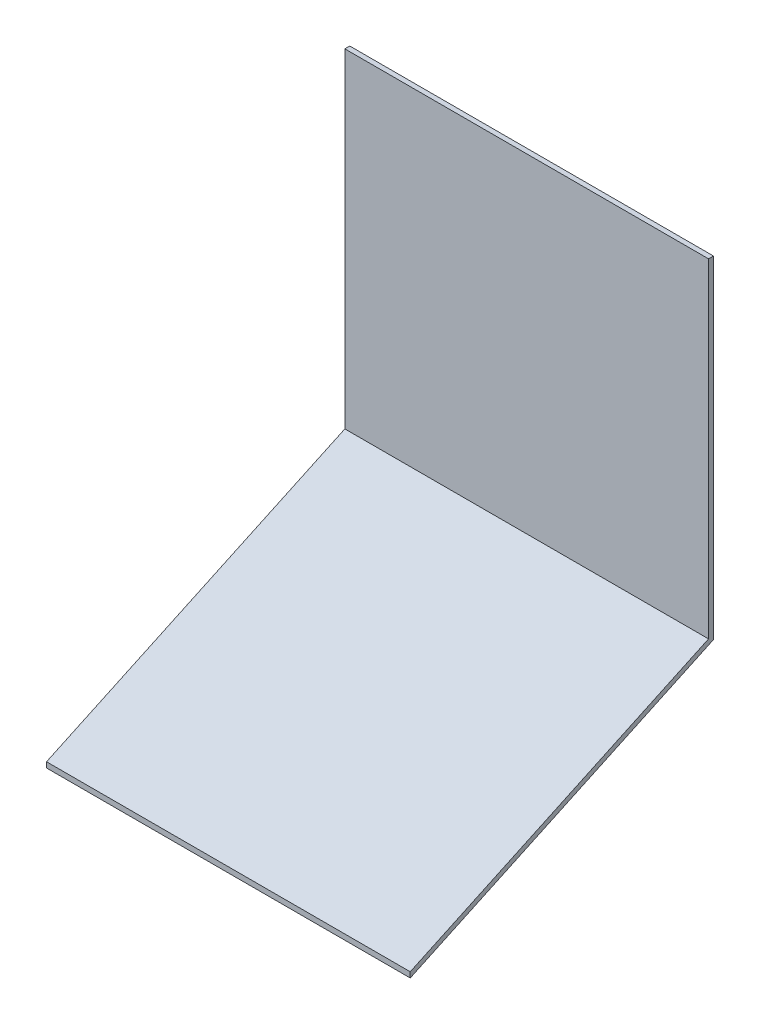
from build123d import *

# Parameters (mm, degrees)
BOSS_EXTRUDE1_DEPTH = 112.268


with BuildPart() as part:
    # Sketch1 → Boss-Extrude1 (new body)
    with BuildSketch(Plane(origin=(0, 0, 0), x_dir=(0, 0, -1), z_dir=(1, 0, 0))):
        Polygon((0, 0), (92.080871163, 42.938015393), (92.080871163, 144.538015393), (93.599791163, 144.538015393), (93.599791163, 41.970356632), (0, -1.675942789), align=None)
    extrude(amount=BOSS_EXTRUDE1_DEPTH)


solid = part.part
